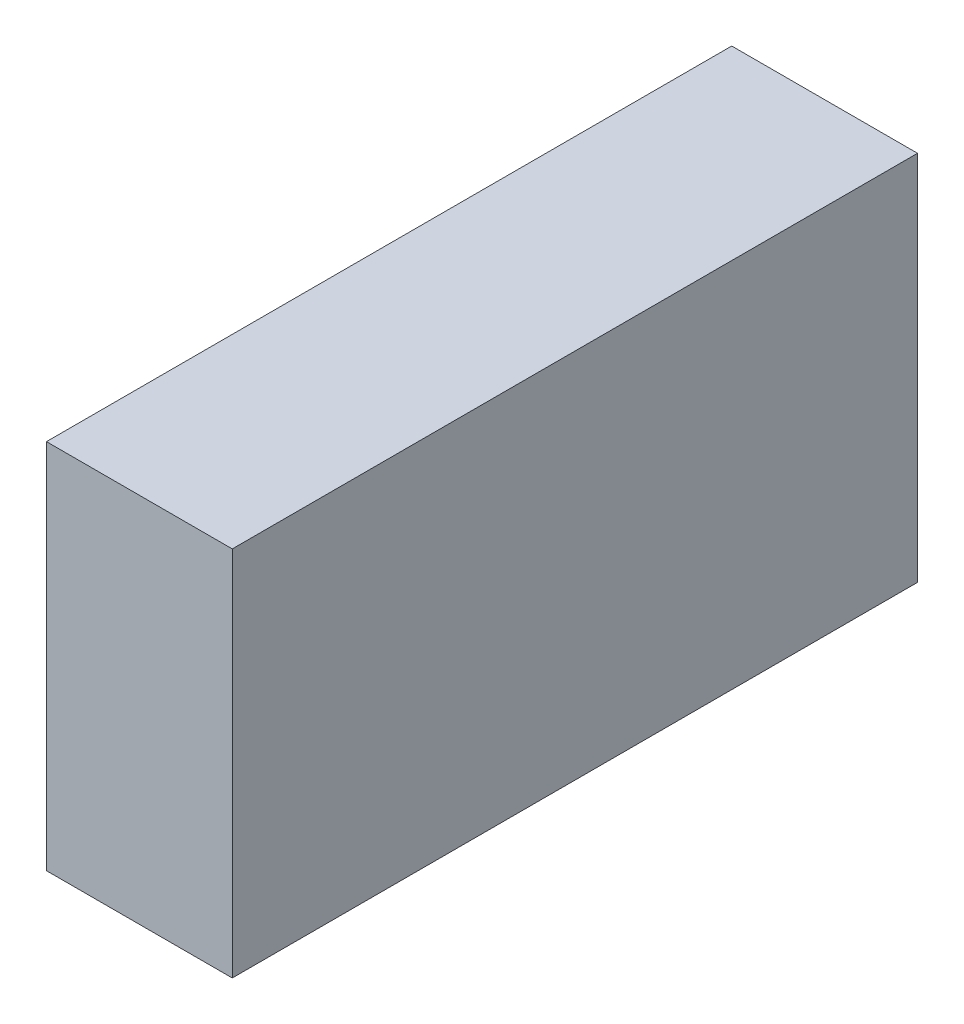
from build123d import *

# Parameters (mm, degrees)
SKETCH1_W           = 7.5
SKETCH1_H           = 27.66
BOSS_EXTRUDE1_DEPTH = 25
SKETCH2_W           = 7.5
SKETCH2_H           = 27.66
CUT_EXTRUDE1_DEPTH  = 10


with BuildPart() as part:
    # Sketch1 → Boss-Extrude1 (new body)
    with BuildSketch(Plane(origin=(0, 0, 0), x_dir=(1, 0, 0), z_dir=(0, 1, 0))):
        with Locations((3.75, 13.83)):
            Rectangle(SKETCH1_W, SKETCH1_H)
    extrude(amount=BOSS_EXTRUDE1_DEPTH)

    # Sketch2 → Cut-Extrude1 (cut)
    with BuildSketch(Plane.XZ):
        with Locations((3.75, -13.83)):
            Rectangle(SKETCH2_W, SKETCH2_H)
    extrude(amount=-CUT_EXTRUDE1_DEPTH, mode=Mode.SUBTRACT)


solid = part.part
